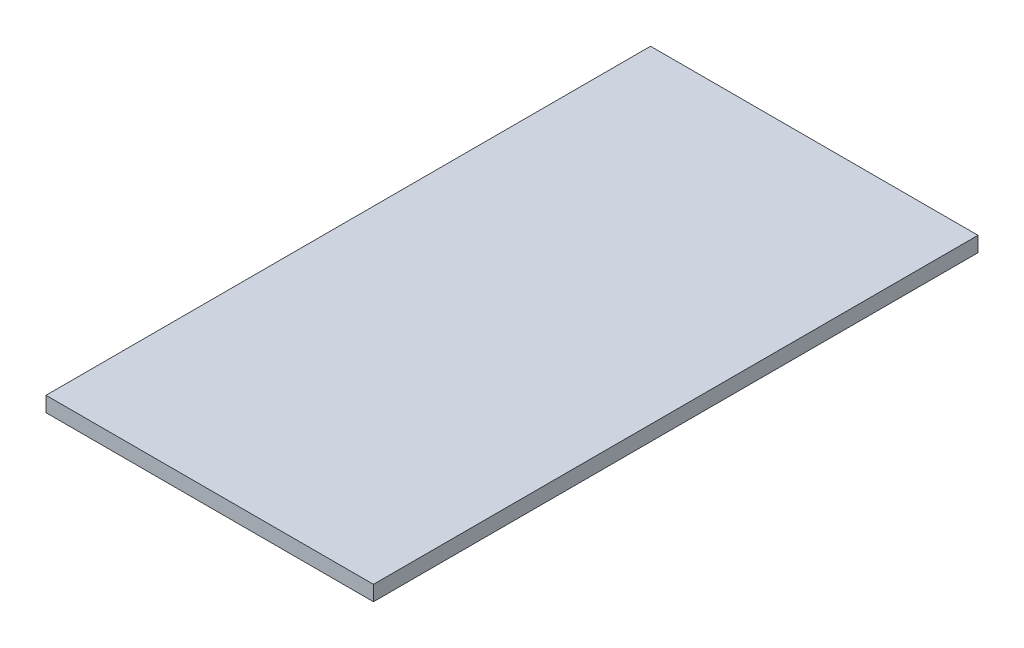
from build123d import *

# Parameters (mm, degrees)
SKETCH1_W           = 65
SKETCH1_H           = 120
BOSS_EXTRUDE1_DEPTH = 2
SKETCH2_W           = 65
SKETCH2_H           = 120
BOSS_EXTRUDE3_DEPTH = 1


with BuildPart() as part:
    # Sketch1 → Boss-Extrude1 (new body)
    with BuildSketch(Plane(origin=(0, 0, 0), x_dir=(1, 0, 0), z_dir=(0, 1, 0))):
        with Locations((-44.487199396, 6.264315183)):
            Rectangle(SKETCH1_W, SKETCH1_H)
    extrude(amount=BOSS_EXTRUDE1_DEPTH)

    # Sketch2 → Boss-Extrude3 (add)
    with BuildSketch(Plane(origin=(0, 2, 0), x_dir=(1, 0, 0), z_dir=(0, 1, 0))):
        with Locations((-44.487199396, 6.264315183)):
            Rectangle(SKETCH2_W, SKETCH2_H)
    extrude(amount=BOSS_EXTRUDE3_DEPTH)


solid = part.part
